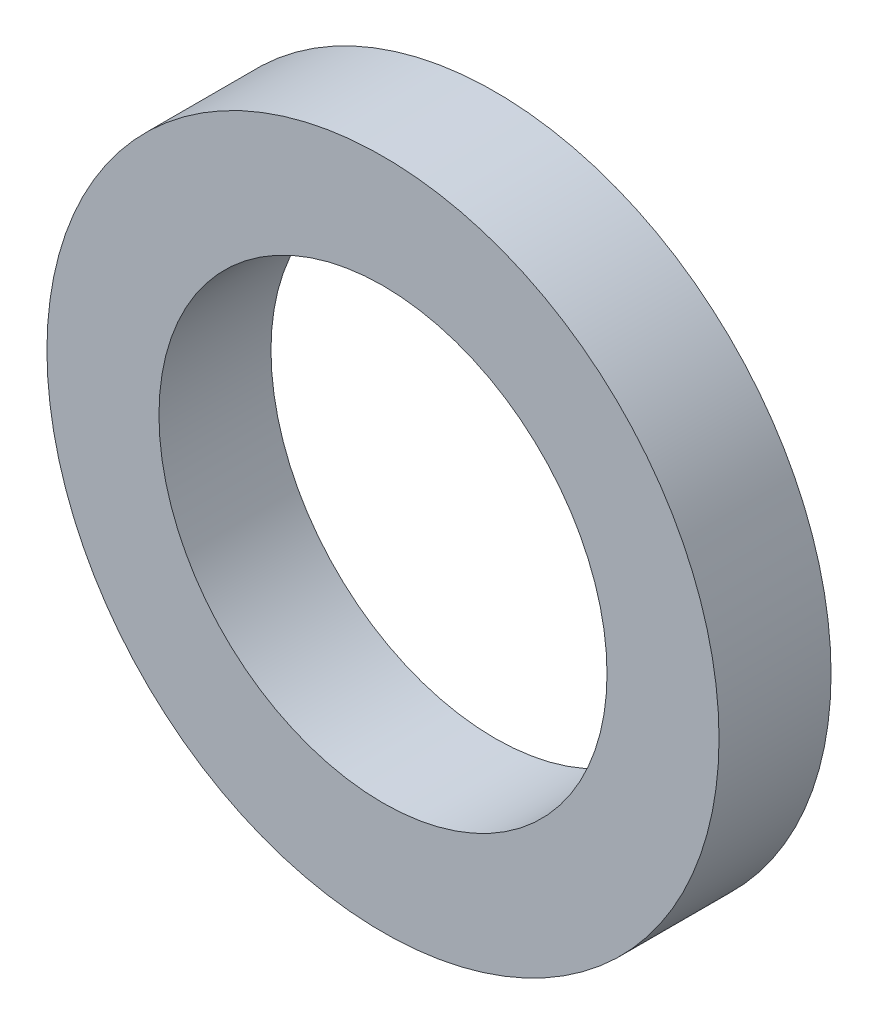
from build123d import *

# Parameters (mm, degrees)
SKETCH1_R           = 15
SKETCH1_R_2         = 10
BOSS_EXTRUDE2_DEPTH = 5


with BuildPart() as part:
    # Sketch1 → Boss-Extrude2 (new body)
    with BuildSketch(Plane.XY):
        Circle(SKETCH1_R)
        Circle(SKETCH1_R_2, mode=Mode.SUBTRACT)
    extrude(amount=BOSS_EXTRUDE2_DEPTH)


solid = part.part
